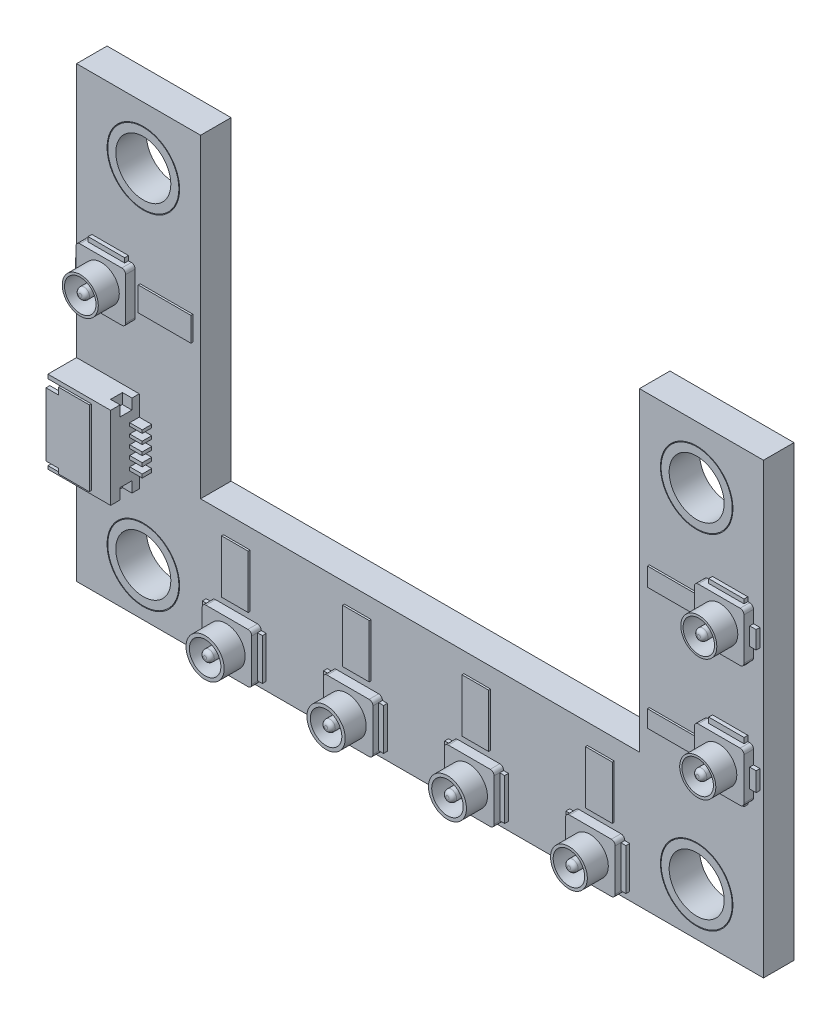
from build123d import *

# Parameters (mm, degrees)
EXTRUDE_1_DEPTH     = 1.6
SKETCH_3_R          = 1.90000381
CUT_EXTRUDE_1_DEPTH = 1.6
SKETCH_4_W          = 3.286766574
SKETCH_4_H          = 4.31606144
EXTRUDE_2_DEPTH     = 1.5
SKETCH_5_W          = 0.622650464
SKETCH_5_H          = 0.561242288
SKETCH_5_H_2        = 0.546297911
CUT_EXTRUDE_2_DEPTH = 0.5
SKETCH_6_W          = 0.653701602
SKETCH_6_H          = 0.184029818
SKETCH_6_H_2        = 0.188872708
SKETCH_6_H_3        = 0.172952076
SKETCH_6_H_4        = 0.159492612
SKETCH_6_H_5        = 0.162739772
EXTRUDE_3_DEPTH     = 0.5
SKETCH_7_W          = 1.431134253
SKETCH_7_H          = 3.941311568
CUT_EXTRUDE_3_DEPTH = 2
SKETCH_9_W          = 1.237183814
SKETCH_9_H          = 0.308254553
SKETCH_9_H_2        = 0.274929736
SKETCH_9_W_2        = 1.237183813
SKETCH_9_H_3        = 0.312420155
SKETCH_9_H_4        = 0.329082563
SKETCH_9_H_5        = 0.279095339
CUT_EXTRUDE_4_DEPTH = 2.5
EXTRUDE_6_DEPTH     = 0.1
SKETCH_11_W         = 2.6001016
SKETCH_11_H         = 2.599873
SKETCH_11_W_2       = 2.599873
SKETCH_11_H_2       = 2.6001016
SKETCH_11_H_3       = 2.600101601
EXTRUDE_7_DEPTH     = 0.5
SKETCH_12_R         = 1.00005245
SKETCH_12_R_2       = 1.003700126
SKETCH_12_R_3       = 0.995184943
SKETCH_12_R_4       = 0.964451506
SKETCH_12_R_5       = 0.946211607
SKETCH_12_R_6       = 0.943298132
SKETCH_12_R_7       = 0.945320033
EXTRUDE_8_DEPTH     = 1.1
SKETCH_13_R         = 0.82549351
SKETCH_13_R_2       = 0.280955332
CUT_EXTRUDE_5_DEPTH = 1.1
SKETCH_14_W         = 0.289256854
SKETCH_14_H         = 2.178171481
SKETCH_14_W_2       = 0.257526133
SKETCH_14_W_3       = 0.584667081
SKETCH_14_H_2       = 0.124793188
SKETCH_14_W_4       = 0.289256853
SKETCH_14_W_5       = 0.257526134
SKETCH_14_W_6       = 0.584667082
SKETCH_14_H_3       = 0.124793189
SKETCH_14_W_7       = 0.336897415
SKETCH_14_H_4       = 0.93051267
SKETCH_14_H_5       = 0.995685527
SKETCH_14_W_8       = 1.854464294
SKETCH_14_H_6       = 0.285333123
SKETCH_14_H_7       = 0.260209925
SKETCH_14_H_8       = 0.220111954
SKETCH_14_H_9       = 0.201906913
SKETCH_14_W_9       = 0.31596979
SKETCH_14_H_10      = 0.540501756
SKETCH_14_W_10      = 1.914234091
SKETCH_14_H_11      = 0.243359321
SKETCH_14_H_12      = 0.240137927
EXTRUDE_9_DEPTH     = 0.2
FILLET_1_R          = 0.2
FILLET_2_R          = 0.2
SKETCH_15_R         = 1.862671309
SKETCH_15_R_2       = 1.441693382
EXTRUDE_10_DEPTH    = 1.6
EXTRUDE_10_2_DEPTH  = 1.6
EXTRUDE_10_3_DEPTH  = 1.6
EXTRUDE_10_4_DEPTH  = 1.6
SKETCH_16_W         = 1.400115898
SKETCH_16_H         = 2.786638437
SKETCH_16_W_2       = 2.764850224
SKETCH_16_H_2       = 1.266010365
SKETCH_16_W_3       = 2.599711344
SKETCH_16_H_3       = 0.966012958
SKETCH_16_H_4       = 0.887837052
SKETCH_16_W_4       = 1.400115897
EXTRUDE_11_DEPTH    = 0.1


with BuildPart() as part:
    # 草图2 → 凸台-拉伸1 (new body)
    with BuildSketch(Plane.XY):
        Polygon((7.77000254, 24.892049784), (7.77000193, 8.392046951), (30.77000266, 8.392049646), (30.77000266, 24.892049784), (37.27000254, 24.892049784), (37.27000254, 1.392049784), (1.27000254, 1.392049784), (1.27000254, 24.892049784), align=None)
    extrude(amount=EXTRUDE_1_DEPTH)

    # 草图3 → 切除-拉伸1 (cut)
    with BuildSketch(Plane.XY.offset(1.6)):
        with Locations((4.77001016, 21.892044704)):
            Circle(SKETCH_3_R)
        with Locations((33.77006858, 21.892044704)):
            Circle(SKETCH_3_R)
        with Locations((33.77000254, 3.892049784)):
            Circle(SKETCH_3_R)
        with Locations((4.77000254, 3.892049784)):
            Circle(SKETCH_3_R)
    extrude(amount=-CUT_EXTRUDE_1_DEPTH, mode=Mode.SUBTRACT)

    # 草图4 → 凸台-拉伸2 (add)
    with BuildSketch(Plane.XY.offset(1.6)):
        with Locations((2.913385827, 9.391965188)):
            Rectangle(SKETCH_4_W, SKETCH_4_H)
    extrude(amount=EXTRUDE_2_DEPTH)

    # 草图5 → 切除-拉伸2 (cut)
    with BuildSketch(Plane(origin=(4.556769114, 0, 0), x_dir=(0, 0, -1), z_dir=(1, 0, 0))):
        with Locations((-2.293875887, 7.514555612)):
            Rectangle(SKETCH_5_W, SKETCH_5_H)
        with Locations((-2.293875887, 11.276846953)):
            Rectangle(SKETCH_5_W, SKETCH_5_H_2)
    extrude(amount=-CUT_EXTRUDE_2_DEPTH, mode=Mode.SUBTRACT)

    # 草图6 → 凸台-拉伸3 (add)
    with BuildSketch(Plane.XY.offset(1.6)):
        with Locations((4.883619915, 8.393973252)):
            Rectangle(SKETCH_6_W, SKETCH_6_H)
        with Locations((4.883619915, 8.904898142)):
            Rectangle(SKETCH_6_W, SKETCH_6_H_2)
        with Locations((4.883619915, 9.402355538)):
            Rectangle(SKETCH_6_W, SKETCH_6_H_3)
        with Locations((4.883619915, 9.896181682)):
            Rectangle(SKETCH_6_W, SKETCH_6_H_4)
        with Locations((4.883619915, 10.408598561)):
            Rectangle(SKETCH_6_W, SKETCH_6_H_5)
    extrude(amount=EXTRUDE_3_DEPTH)

    # 草图7 → 切除-拉伸3 (cut)
    with BuildSketch(Plane.ZY.offset(-1.27000254)):
        with Locations((2.501329422, 9.366910549)):
            Rectangle(SKETCH_7_W, SKETCH_7_H)
    extrude(amount=-CUT_EXTRUDE_3_DEPTH, mode=Mode.SUBTRACT)

    # 草图9 → 切除-拉伸4 (cut)
    with BuildSketch(Plane.ZY.offset(-1.27000254)):
        with Locations((2.312195252, 10.825065324)):
            Rectangle(SKETCH_9_W, SKETCH_9_H)
        with Locations((2.312195252, 10.087753758)):
            Rectangle(SKETCH_9_W, SKETCH_9_H_2)
        with Locations((2.303864048, 9.369187402)):
            Rectangle(SKETCH_9_W_2, SKETCH_9_H_3)
        with Locations((2.303864048, 8.681863061)):
            Rectangle(SKETCH_9_W_2, SKETCH_9_H_4)
        with Locations((2.308029649, 8.052857149)):
            Rectangle(SKETCH_9_W_2, SKETCH_9_H_5)
    extrude(amount=-CUT_EXTRUDE_4_DEPTH, mode=Mode.SUBTRACT)

    # 草图10 → 凸台-拉伸6 (add, symmetric)
    with BuildSketch(Plane.XY.offset(3.1)):
        Polygon((1.931471367, 11.337566333), (1.931471367, 10.9791926), (1.27000254, 10.9791926), (1.27000254, 7.654782123), (1.931471367, 7.654782123), (1.931471367, 7.396254765), (3.541160322, 7.396254765), (3.541160322, 11.337566333), align=None)
    extrude(amount=EXTRUDE_6_DEPTH, both=True)

    # 草图11 → 凸台-拉伸7 (add)
    with BuildSketch(Plane.XY.offset(1.6)):
        with Locations((9.651968504, 2.905930912)):
            Rectangle(SKETCH_11_W, SKETCH_11_H)
        with Locations((16.001981204, 2.905930912)):
            Rectangle(SKETCH_11_W, SKETCH_11_H)
        with Locations((22.351993904, 2.905930912)):
            Rectangle(SKETCH_11_W, SKETCH_11_H)
        with Locations((28.702006604, 2.905930912)):
            Rectangle(SKETCH_11_W, SKETCH_11_H)
        with Locations((35.448145796, 10.413970028)):
            Rectangle(SKETCH_11_W_2, SKETCH_11_H_2)
        with Locations((35.448145796, 16.763982728)):
            Rectangle(SKETCH_11_W_2, SKETCH_11_H_2)
        with Locations((3.042989586, 16.003225807)):
            Rectangle(SKETCH_11_W_2, SKETCH_11_H_3)
    extrude(amount=EXTRUDE_7_DEPTH)

    # 草图12 → 凸台-拉伸8 (add)
    with BuildSketch(Plane.XY.offset(2.1)):
        with Locations((9.608029399, 2.901928055)):
            Circle(SKETCH_12_R)
        with Locations((15.948331878, 2.901928055)):
            Circle(SKETCH_12_R_2)
        with Locations((22.309434804, 2.901928055)):
            Circle(SKETCH_12_R_3)
        with Locations((28.675142973, 2.901928055)):
            Circle(SKETCH_12_R_4)
        with Locations((35.426664872, 10.402332529)):
            Circle(SKETCH_12_R_5)
        with Locations((35.481669753, 16.813813553)):
            Circle(SKETCH_12_R_6)
        with Locations((3.065289136, 16.07320377)):
            Circle(SKETCH_12_R_7)
    extrude(amount=EXTRUDE_8_DEPTH)

    # 草图13 → 切除-拉伸5 (cut)
    with BuildSketch(Plane.XY.offset(3.2)):
        with Locations((9.608029399, 2.901928055)):
            Circle(SKETCH_13_R)
        with Locations((9.608029399, 2.901928055)):
            Circle(SKETCH_13_R_2, mode=Mode.SUBTRACT)
        with Locations((15.948331878, 2.901928055)):
            Circle(SKETCH_13_R)
        with Locations((15.948331878, 2.901928055)):
            Circle(SKETCH_13_R_2, mode=Mode.SUBTRACT)
        with Locations((22.309434804, 2.901928055)):
            Circle(SKETCH_13_R)
        with Locations((22.309434804, 2.901928055)):
            Circle(SKETCH_13_R_2, mode=Mode.SUBTRACT)
        with Locations((28.675142973, 2.901928055)):
            Circle(SKETCH_13_R)
        with Locations((28.675142973, 2.901928055)):
            Circle(SKETCH_13_R_2, mode=Mode.SUBTRACT)
        with Locations((35.421369523, 10.414451157)):
            Circle(SKETCH_13_R)
        with Locations((35.421369523, 10.414451157)):
            Circle(SKETCH_13_R_2, mode=Mode.SUBTRACT)
        with Locations((35.48184563, 16.802831172)):
            Circle(SKETCH_13_R)
        with Locations((35.48184563, 16.802831172)):
            Circle(SKETCH_13_R_2, mode=Mode.SUBTRACT)
        with Locations((3.065289136, 16.07320377)):
            Circle(SKETCH_13_R)
        with Locations((3.065289136, 16.07320377)):
            Circle(SKETCH_13_R_2, mode=Mode.SUBTRACT)
    extrude(amount=-CUT_EXTRUDE_5_DEPTH, mode=Mode.SUBTRACT)

    # 草图14 → 凸台-拉伸9 (add)
    with BuildSketch(Plane.XY.offset(1.6)):
        with Locations((8.207289277, 2.914208777)):
            Rectangle(SKETCH_14_W, SKETCH_14_H)
        with Locations((11.08078237, 2.914208777)):
            Rectangle(SKETCH_14_W_2, SKETCH_14_H)
        with Locations((9.65616525, 1.543597818)):
            Rectangle(SKETCH_14_W_3, SKETCH_14_H_2)
        with Locations((14.554720027, 2.914332425)):
            Rectangle(SKETCH_14_W_4, SKETCH_14_H)
        with Locations((17.42821312, 2.914332425)):
            Rectangle(SKETCH_14_W_5, SKETCH_14_H)
        with Locations((16.003595999, 1.543721465)):
            Rectangle(SKETCH_14_W_6, SKETCH_14_H_2)
        with Locations((20.905254038, 2.909124432)):
            Rectangle(SKETCH_14_W_4, SKETCH_14_H)
        with Locations((23.778747131, 2.909124432)):
            Rectangle(SKETCH_14_W_2, SKETCH_14_H)
        with Locations((22.35413001, 1.538513473)):
            Rectangle(SKETCH_14_W_6, SKETCH_14_H_3)
        with Locations((27.25905421, 2.905917786)):
            Rectangle(SKETCH_14_W_4, SKETCH_14_H)
        with Locations((30.132547303, 2.905917786)):
            Rectangle(SKETCH_14_W_2, SKETCH_14_H)
        with Locations((28.707930182, 1.535306828)):
            Rectangle(SKETCH_14_W_6, SKETCH_14_H_3)
        with Locations((36.916531003, 16.747069402)):
            Rectangle(SKETCH_14_W_7, SKETCH_14_H_4)
        with Locations((36.916531003, 10.306688555)):
            Rectangle(SKETCH_14_W_7, SKETCH_14_H_5)
        with Locations((35.524386909, 11.85668739)):
            Rectangle(SKETCH_14_W_8, SKETCH_14_H_6)
        with Locations((35.524386909, 8.983814266)):
            Rectangle(SKETCH_14_W_8, SKETCH_14_H_7)
        with Locations((35.524386909, 18.174089505)):
            Rectangle(SKETCH_14_W_8, SKETCH_14_H_8)
        with Locations((35.524386909, 15.362978471)):
            Rectangle(SKETCH_14_W_8, SKETCH_14_H_9)
        with Locations((1.585068191, 16.011562189)):
            Rectangle(SKETCH_14_W_9, SKETCH_14_H_10)
        with Locations((3.032957503, 14.581495346)):
            Rectangle(SKETCH_14_W_10, SKETCH_14_H_11)
        with Locations((3.032957503, 17.423345571)):
            Rectangle(SKETCH_14_W_10, SKETCH_14_H_12)
    extrude(amount=EXTRUDE_9_DEPTH)

    # 圆角1
    fillet_1_edges = [part.edges().sort_by_distance(p)[0] for p in [
        (8.351917704, 4.205867412, 1.85),
        (8.351917704, 1.605994412, 1.85),
        (10.952019304, 1.605994412, 1.85),
        (10.952019304, 4.205867412, 1.85),
        (14.701930404, 4.205867412, 1.85),
        (14.701930404, 1.605994412, 1.85),
        (17.302032004, 1.605994412, 1.85),
        (17.302032004, 4.205867412, 1.85),
        (21.051943104, 4.205867412, 1.85),
        (21.051943104, 1.605994412, 1.85),
        (23.652044704, 1.605994412, 1.85),
        (23.652044704, 4.205867412, 1.85),
        (27.401955804, 4.205867412, 1.85),
        (27.401955804, 1.605994412, 1.85),
        (30.002057404, 1.605994412, 1.85),
        (30.002057404, 4.205867412, 1.85),
        (34.148209296, 11.714020828, 1.85),
        (34.148209296, 9.113919228, 1.85),
        (36.748082296, 9.113919228, 1.85),
        (36.748082296, 11.714020828, 1.85),
        (34.148209296, 18.064033528, 1.85),
        (34.148209296, 15.463931928, 1.85),
        (36.748082296, 15.463931928, 1.85),
        (36.748082296, 18.064033528, 1.85),
        (4.342926086, 14.703175006, 1.85),
        (4.342926086, 17.303276607, 1.85),
        (1.743053086, 17.303276607, 1.85),
        (1.743053086, 14.703175006, 1.85),
    ]]
    fillet(fillet_1_edges, radius=FILLET_1_R)

    # 圆角2
    fillet_2_edges = [part.edges().sort_by_distance(p)[0] for p in [
        (2.784333804, 16.07320377, 3.2),
        (35.200890298, 16.802831172, 3.2),
        (35.14041419, 10.414451157, 3.2),
        (28.394187641, 2.901928055, 3.2),
        (22.028479471, 2.901928055, 3.2),
        (15.667376545, 2.901928055, 3.2),
        (9.327074066, 2.901928055, 3.2),
    ]]
    fillet(fillet_2_edges, radius=FILLET_2_R)

    # 草图16 → 凸台-拉伸11 (add)
    with BuildSketch(Plane.XY.offset(1.6)):
        with Locations((16.009679287, 5.989754457)):
            Rectangle(SKETCH_16_W, SKETCH_16_H)
        with Locations((5.983129222, 15.932168475)):
            Rectangle(SKETCH_16_W_2, SKETCH_16_H_2)
        with Locations((32.589780485, 16.66953241)):
            Rectangle(SKETCH_16_W_3, SKETCH_16_H_3)
        with Locations((32.589780485, 10.23097296)):
            Rectangle(SKETCH_16_W_3, SKETCH_16_H_4)
        with Locations((9.668377673, 5.969364419)):
            Rectangle(SKETCH_16_W_4, SKETCH_16_H)
        with Locations((22.269420752, 5.96256774)):
            Rectangle(SKETCH_16_W_4, SKETCH_16_H)
        with Locations((28.746820587, 5.937818054)):
            Rectangle(SKETCH_16_W, SKETCH_16_H)
    extrude(amount=EXTRUDE_11_DEPTH)


with BuildPart() as body_2:
    # 草图15 → 凸台-拉伸10 (new body, through all)
    with BuildSketch(Plane.XY.offset(1.6)):
        with Locations((4.77001016, 21.892044704)):
            Circle(SKETCH_15_R)
        with Locations((4.77001016, 21.892044704)):
            Circle(SKETCH_15_R_2, mode=Mode.SUBTRACT)
    extrude(amount=-EXTRUDE_10_DEPTH)


with BuildPart() as body_3:
    # 草图15 → Extrude 10 2 (new body, through all)
    with BuildSketch(Plane.XY.offset(1.6)):
        with Locations((4.77000254, 3.892049784)):
            Circle(SKETCH_15_R)
        with Locations((4.77000254, 3.892049784)):
            Circle(SKETCH_15_R_2, mode=Mode.SUBTRACT)
    extrude(amount=-EXTRUDE_10_2_DEPTH)


with BuildPart() as body_4:
    # 草图15 → Extrude 10 3 (new body, through all)
    with BuildSketch(Plane.XY.offset(1.6)):
        with Locations((33.77000254, 3.892049784)):
            Circle(SKETCH_15_R)
        with Locations((33.77000254, 3.892049784)):
            Circle(SKETCH_15_R_2, mode=Mode.SUBTRACT)
    extrude(amount=-EXTRUDE_10_3_DEPTH)


with BuildPart() as body_5:
    # 草图15 → Extrude 10 4 (new body, through all)
    with BuildSketch(Plane.XY.offset(1.6)):
        with Locations((33.77006858, 21.892044704)):
            Circle(SKETCH_15_R)
        with Locations((33.77006858, 21.892044704)):
            Circle(SKETCH_15_R_2, mode=Mode.SUBTRACT)
    extrude(amount=-EXTRUDE_10_4_DEPTH)


solid = Compound([part.part, body_2.part, body_3.part, body_4.part, body_5.part])
